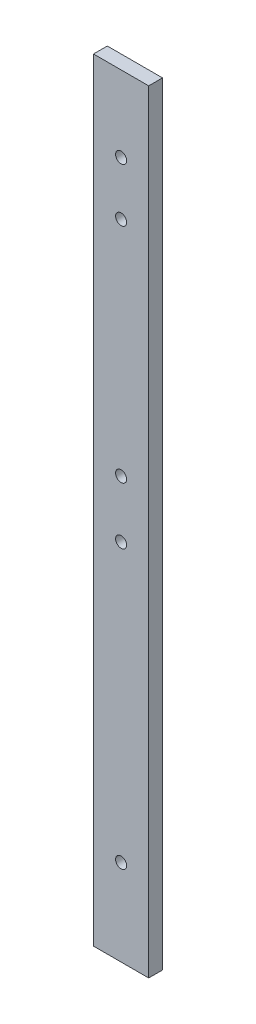
from build123d import *

# Parameters (mm, degrees)
SKETCH1_W           = 25.4
SKETCH1_H           = 355.6
BOSS_EXTRUDE1_DEPTH = 6.35
SKETCH2_R           = 2.54
CUT_EXTRUDE1_DEPTH  = 7.35


with BuildPart() as part:
    # Sketch1 → Boss-Extrude1 (new body)
    with BuildSketch(Plane.XY):
        Rectangle(SKETCH1_W, SKETCH1_H)
    extrude(amount=BOSS_EXTRUDE1_DEPTH)

    # Sketch2 → Cut-Extrude1 (cut, through all)
    with BuildSketch(Plane.XY.offset(6.35)):
        with Locations((0, 142.875)):
            Circle(SKETCH2_R)
        with Locations((0, 118.26875)):
            Circle(SKETCH2_R)
        with Locations((0, 15.875)):
            Circle(SKETCH2_R)
        with Locations((0, -10.31875)):
            Circle(SKETCH2_R)
        with Locations((0, -138.1125)):
            Circle(SKETCH2_R)
    extrude(amount=-CUT_EXTRUDE1_DEPTH, mode=Mode.SUBTRACT)


solid = part.part
